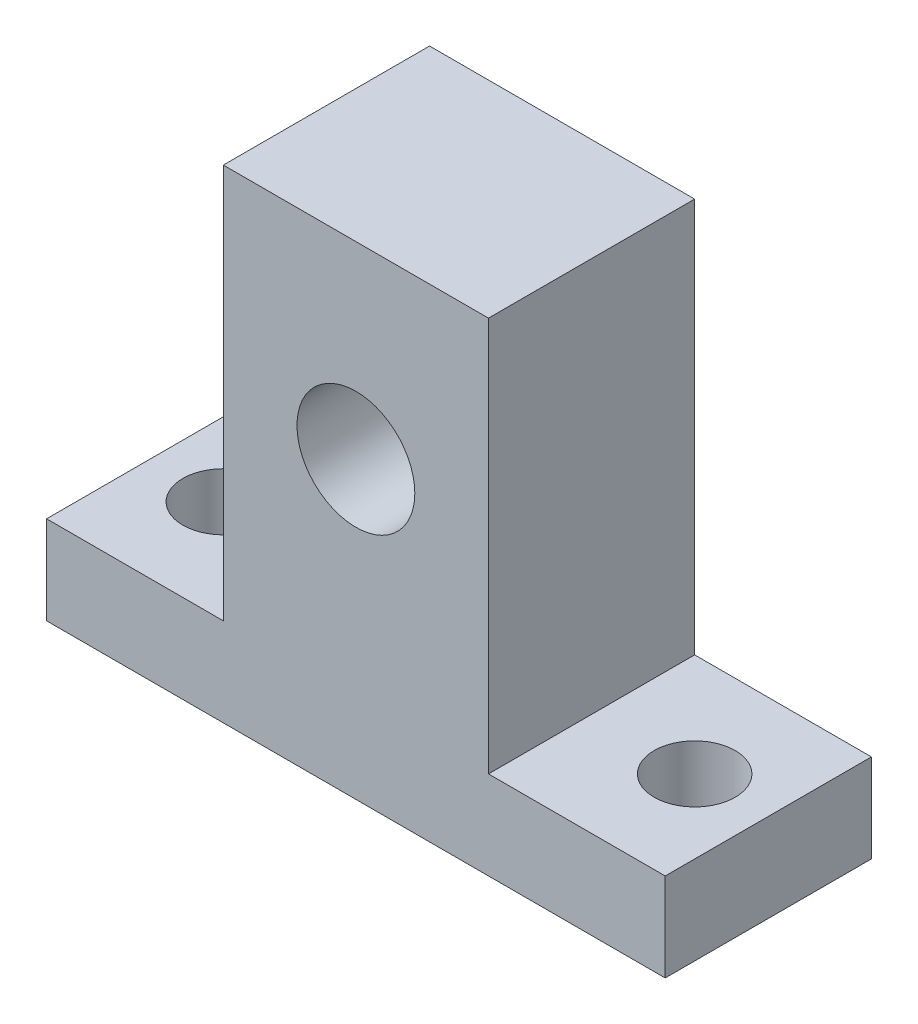
from build123d import *

# Parameters (mm, degrees)
SKETCH1_R           = 4
BOSS_EXTRUDE1_DEPTH = 14
SKETCH2_R           = 2.75
CUT_EXTRUDE1_DEPTH  = 7


with BuildPart() as part:
    # Sketch1 → Boss-Extrude1 (new body)
    with BuildSketch(Plane.XY):
        Polygon((0, 0), (42, 0), (42, 6), (30, 6), (30, 32.8), (12, 32.8), (12, 6), (0, 6), align=None)
        with Locations((21, 20)):
            Circle(SKETCH1_R, mode=Mode.SUBTRACT)
    extrude(amount=BOSS_EXTRUDE1_DEPTH)

    # Sketch2 → Cut-Extrude1 (cut, through all)
    with BuildSketch(Plane(origin=(0, 6, 0), x_dir=(1, 0, 0), z_dir=(0, 1, 0))):
        with Locations((5, -7)):
            Circle(SKETCH2_R)
        with Locations((37, -7)):
            Circle(SKETCH2_R)
    extrude(amount=-CUT_EXTRUDE1_DEPTH, mode=Mode.SUBTRACT)


solid = part.part
